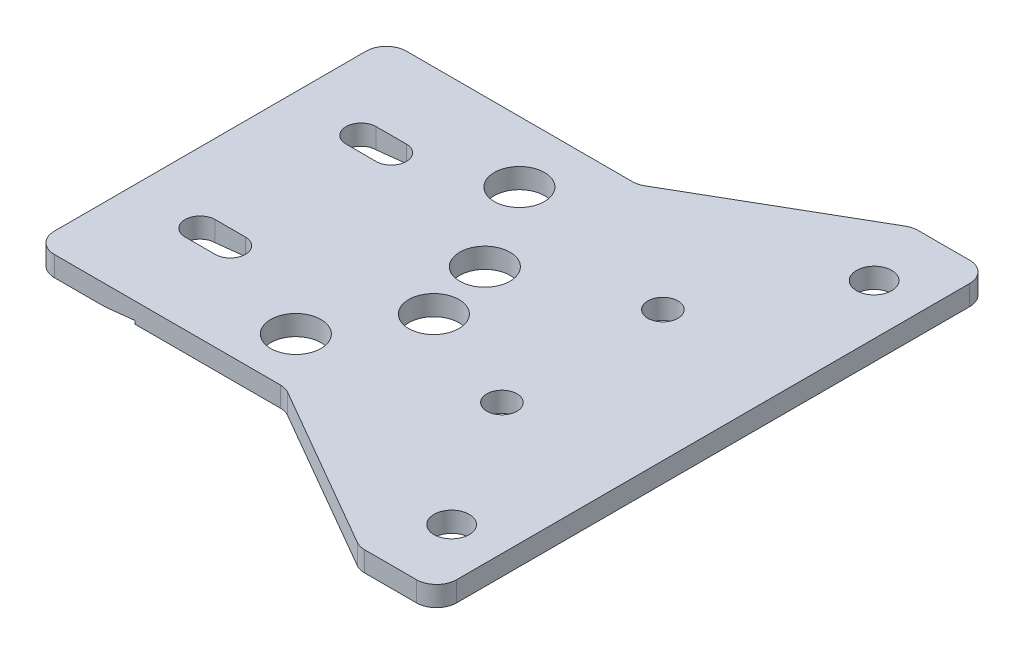
from build123d import *

# Parameters (mm, degrees)
SKETCH_1_W               = 50
SKETCH_1_H               = 55
EXTRUDE_1_DEPTH          = 2
SKETCH_2_R               = 1.5
CUT_EXTRUDE_1_DEPTH      = 38.218946788
CUT_EXTRUDE_2_DEPTH      = 10
CUT_EXTRUDE_3_DEPTH      = 44.465503563
CUT_EXTRUDE_3_DEPTH_BACK = 44.465503563
SKETCH_5_R               = 1.75
CUT_EXTRUDE_4_DEPTH      = 10
CUT_EXTRUDE_5_DEPTH      = 10
SKETCH_7_R               = 2.5
CUT_EXTRUDE_6_DEPTH      = 10
FILLET_1_R               = 2


with BuildPart() as part:
    # 草图1 → 凸台-拉伸1 (new body)
    with BuildSketch(Plane(origin=(0, 0, 0), x_dir=(1, 0, 0), z_dir=(0, 1, 0))):
        Rectangle(SKETCH_1_W, SKETCH_1_H)
    extrude(amount=EXTRUDE_1_DEPTH)

    # 草图2 → 切除-拉伸1 (cut, through all)
    with BuildSketch(Plane(origin=(0, 2, 0), x_dir=(1, 0, 0), z_dir=(0, 1, 0))):
        with Locations((-18, 8)):
            Circle(SKETCH_2_R)
        with Locations((-18, -8)):
            Circle(SKETCH_2_R)
        with Locations((12, -8)):
            Circle(SKETCH_2_R)
        with Locations((12, 8)):
            Circle(SKETCH_2_R)
    extrude(amount=-CUT_EXTRUDE_1_DEPTH, mode=Mode.SUBTRACT)

    # 草图3 → 切除-拉伸2 (cut)
    with BuildSketch(Plane.XZ):
        with BuildLine():
            Line((-18, 9.5), (-15, 9.5))
            ThreePointArc((-15, 9.5), (-13.5, 8), (-15, 6.5))
            Line((-15, 6.5), (-18, 6.5))
            Line((-18, 6.5), (-18, 9.5))
        make_face()
    cut_extrude_2 = extrude(amount=-CUT_EXTRUDE_2_DEPTH, mode=Mode.SUBTRACT)

    # 草图4 → 切除-拉伸3 (cut, two sides: drawn at the far end of the back side and taken through both)
    with BuildSketch(Plane.XY.offset(8).offset(-CUT_EXTRUDE_3_DEPTH_BACK)):
        Polygon((-18, 0), (-15, 0.315312706), (-15, 0), align=None)
    extrude(amount=CUT_EXTRUDE_3_DEPTH + CUT_EXTRUDE_3_DEPTH_BACK, mode=Mode.SUBTRACT)

    # 镜向1: 切除-拉伸2 across plane
    add(cut_extrude_2.mirror(Plane.XY), mode=Mode.SUBTRACT)

    # 草图5 → 切除-拉伸4 (cut)
    with BuildSketch(Plane(origin=(0, 2, 0), x_dir=(1, 0, 0), z_dir=(0, 1, 0))):
        with Locations((20, 21)):
            Circle(SKETCH_5_R)
        with Locations((20, -21)):
            Circle(SKETCH_5_R)
    extrude(amount=-CUT_EXTRUDE_4_DEPTH, mode=Mode.SUBTRACT)

    # 草图6 → 切除-拉伸5 (cut)
    with BuildSketch(Plane(origin=(0, 2, 0), x_dir=(1, 0, 0), z_dir=(0, 1, 0))):
        Polygon((-25, 17.5), (0, 17.5), (17.320508076, 27.5), (-25, 27.5), align=None)
        Polygon((17.320508076, -27.5), (-25, -27.5), (-25, -17.5), (0, -17.5), align=None)
    extrude(amount=-CUT_EXTRUDE_5_DEPTH, mode=Mode.SUBTRACT)

    # 草图7 → 切除-拉伸6 (cut)
    with BuildSketch(Plane.XZ):
        with Locations((-5.685574087, -11.419607443)):
            Circle(SKETCH_7_R)
        with Locations((-0.540616532, -2.844678186)):
            Circle(SKETCH_7_R)
        with Locations((-4.144957554, 12.343977362)):
            Circle(SKETCH_7_R)
        with Locations((1, 3.769048105)):
            Circle(SKETCH_7_R)
    extrude(amount=-CUT_EXTRUDE_6_DEPTH, mode=Mode.SUBTRACT)

    # 圆角1
    fillet_1_edges = [part.edges().sort_by_distance(p)[0] for p in [
        (17.320508076, 1, -27.5),
        (25, 1, -27.5),
        (17.320508076, 1, 27.5),
        (-25, 1, -17.5),
        (0, 1, -17.5),
        (-25, 1, 17.5),
        (25, 1, 27.5),
        (0, 1, 17.5),
    ]]
    fillet(fillet_1_edges, radius=FILLET_1_R)


solid = part.part
